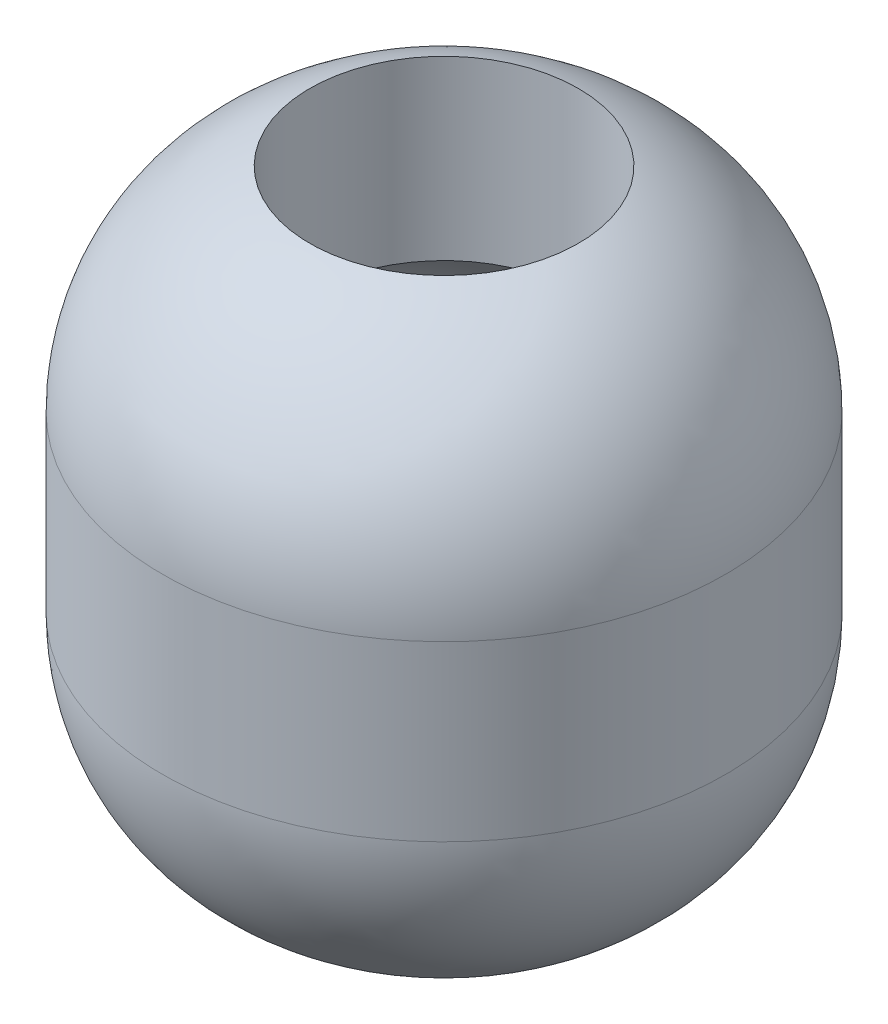
from build123d import *


with BuildPart() as part:
    # Skizze1 → Rotation1 (revolve)
    with BuildSketch(Plane.XY, mode=Mode.PRIVATE) as rotation1_sk:
        with BuildLine():
            Line((-83.5, 410), (-83.5, 300))
            ThreePointArc((-83.5, 300), (-131.181602767, 270.08589765), (-163.5, 224))
            ThreePointArc((-163.5, 224), (-111.918186946, 163.530430528), (-36, 140))
            Line((-36, 140), (-36, 87))
            Line((-36, 87), (-94, 87))
            Line((-94, 87), (-116.406641223, 55))
            ThreePointArc((-116.406641223, 55), (-159.504064003, 105.325051589), (-175, 169.744572198))
            Line((-175, 169.744572198), (-175, 277.524719287))
            ThreePointArc((-175, 277.524719287), (-149.901426418, 358.026194429), (-83.5, 410))
        make_face()
    revolve(rotation1_sk.sketch.rotate(Axis((0, 0, 0), (0, 1, 0)), 270), axis=Axis((0, 0, 0), (0, 1, 0)))  # turned: the seam where the file's is


solid = part.part
